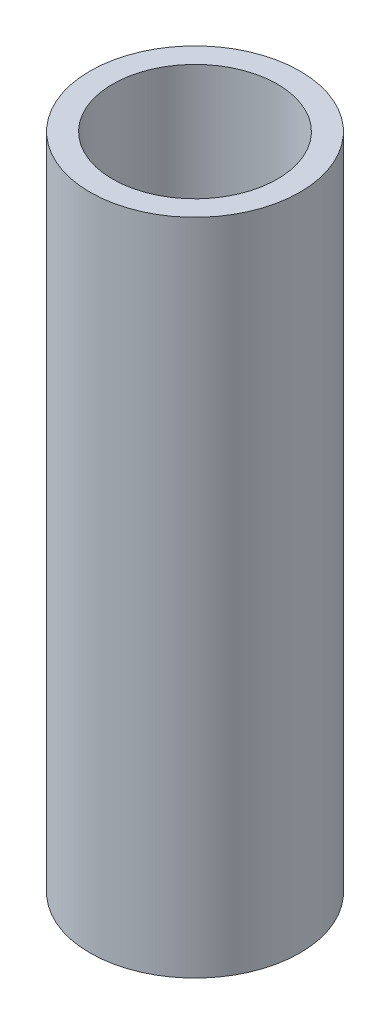
from build123d import *

# Parameters (mm, degrees)
SKETCH1_R           = 24.2824
SKETCH1_R_2         = 19.05
BOSS_EXTRUDE1_DEPTH = 76.2


with BuildPart() as part:
    # Sketch1 → Boss-Extrude1 (new body, symmetric)
    with BuildSketch(Plane(origin=(0, 0, 0), x_dir=(1, 0, 0), z_dir=(0, 1, 0))):
        Circle(SKETCH1_R)
        Circle(SKETCH1_R_2, mode=Mode.SUBTRACT)
    extrude(amount=BOSS_EXTRUDE1_DEPTH, both=True)


solid = part.part
